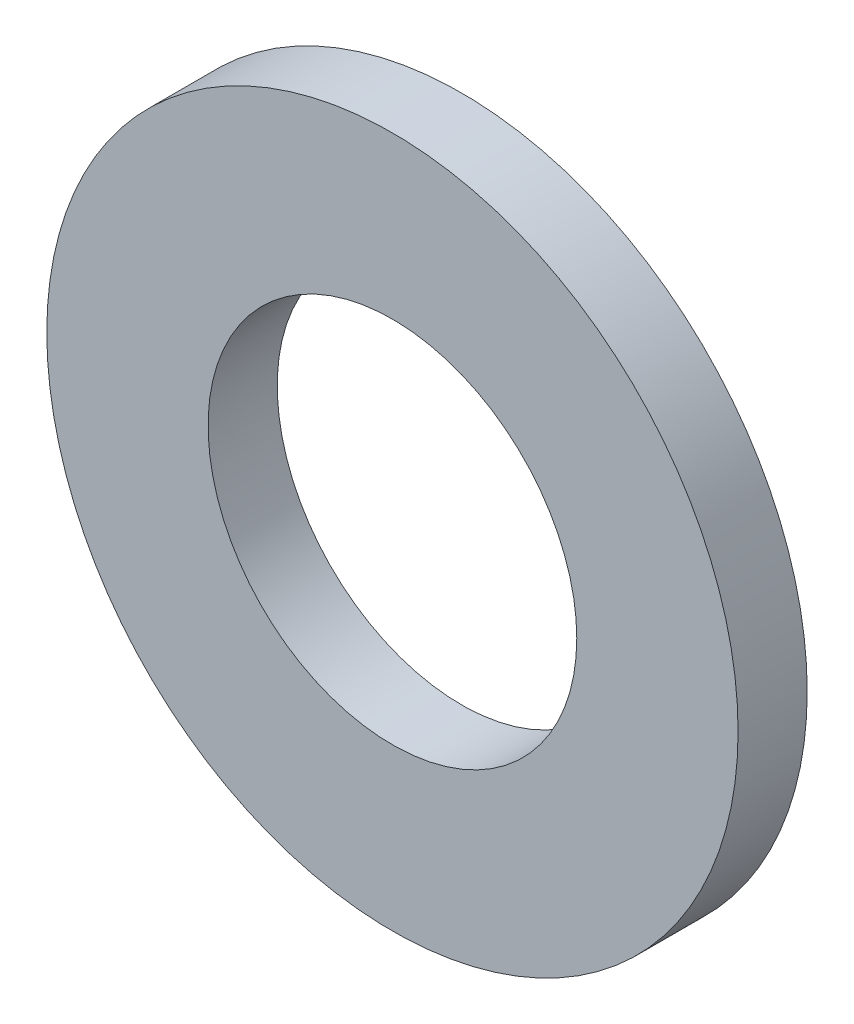
from build123d import *

# Parameters (mm, degrees)
SKETCH3_R                = 3
SKETCH3_R_2              = 1.6
BOSS_EXTRUDE1_DEPTH      = 0.3
BOSS_EXTRUDE1_DEPTH_BACK = 0.3


with BuildPart() as part:
    # Sketch3 → Boss-Extrude1 (new body, two sides)
    with BuildSketch(Plane.XY) as boss_extrude1_sk:
        Circle(SKETCH3_R)
        Circle(SKETCH3_R_2, mode=Mode.SUBTRACT)
    extrude(amount=BOSS_EXTRUDE1_DEPTH)
    extrude(boss_extrude1_sk.sketch, amount=-BOSS_EXTRUDE1_DEPTH_BACK)


solid = part.part
